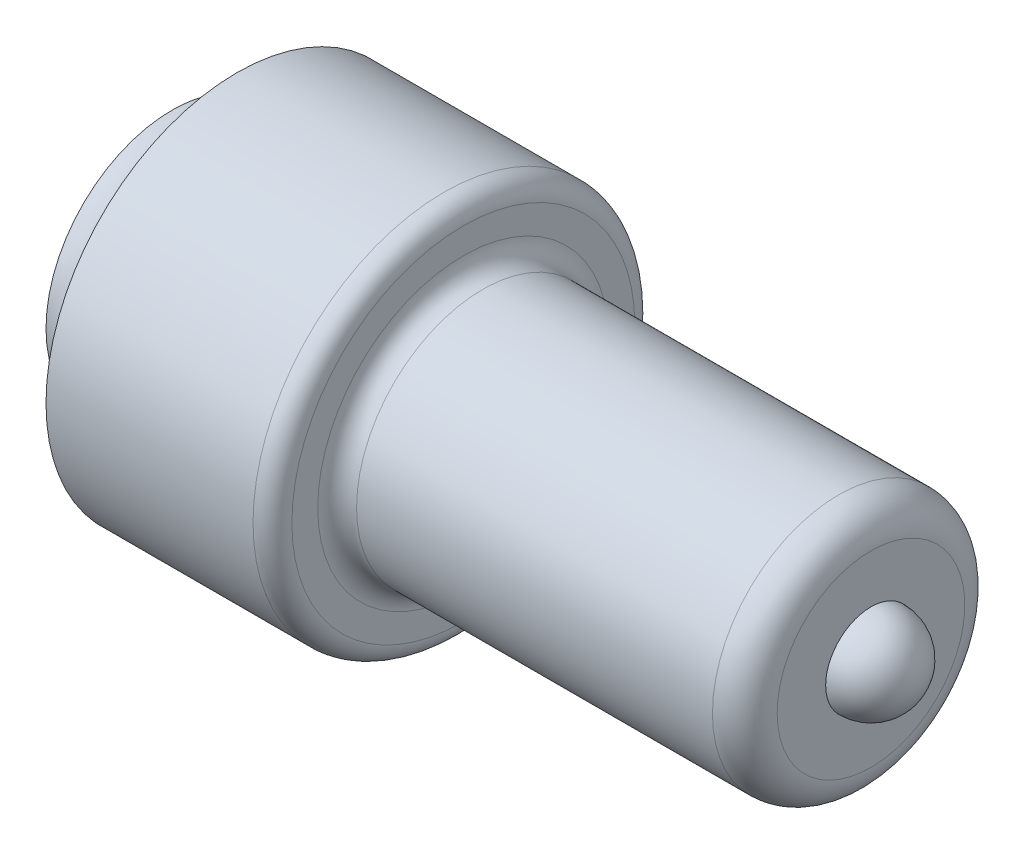
from build123d import *


with BuildPart() as part:
    # Sketch1 → Revolve5 (revolve)
    with BuildSketch(Plane.XY):
        with BuildLine():
            Line((0, 0), (146.05, 0))
            ThreePointArc((146.05, 0), (143.446179285, 6.286179285), (137.16, 8.89))
            Line((137.16, 8.89), (137.16, 18.415))
            ThreePointArc((137.16, 18.415), (135.300128061, 22.905128061), (130.81, 24.765))
            Line((130.81, 24.765), (60.96, 24.765))
            ThreePointArc((60.96, 24.765), (58.265923164, 25.880923164), (57.15, 28.575))
            Line((57.15, 28.575), (57.15, 33.655))
            ThreePointArc((57.15, 33.655), (56.034076836, 36.349076836), (53.34, 37.465))
            Line((53.34, 37.465), (12.7, 37.465))
            ThreePointArc((12.7, 37.465), (8.980256121, 28.484743879), (0, 24.765))
            Line((0, 24.765), (0, 0))
        make_face()
    revolve(axis=Axis((0, 0, 0), (1, 0, 0)))


solid = part.part
